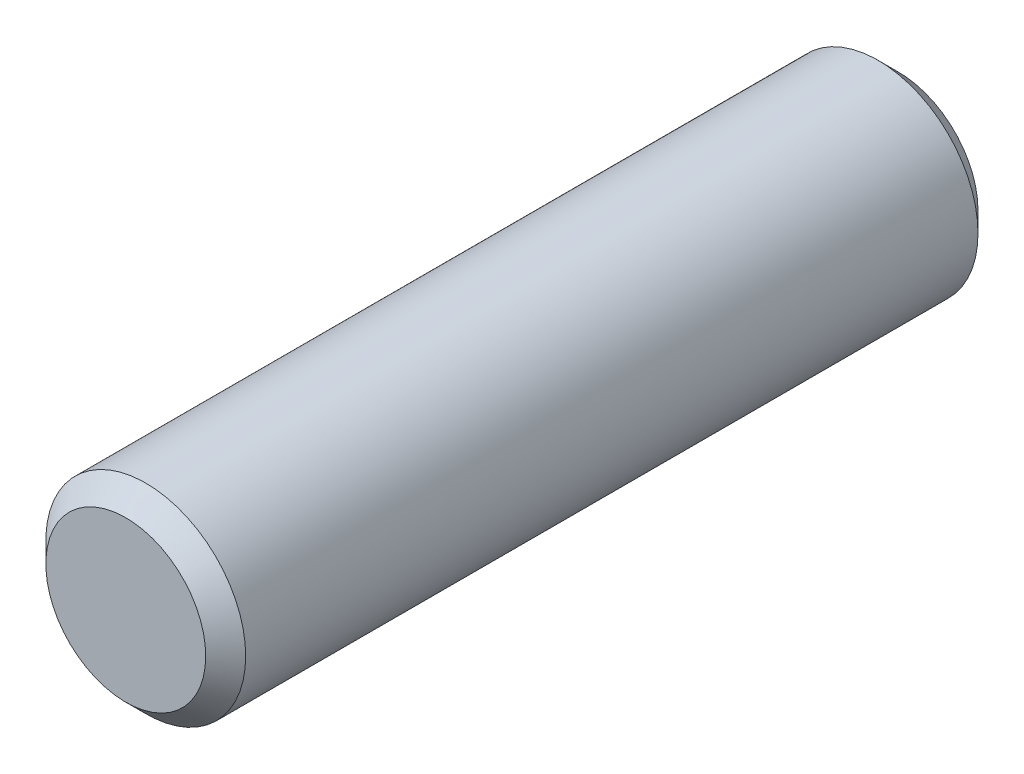
from build123d import *

# Parameters (mm, degrees)
SKETCH3_R           = 7.9375
BOSS_EXTRUDE1_DEPTH = 30.675
CHAMFER1_SIZE       = 1.5875


with BuildPart() as part:
    # Sketch3 → Boss-Extrude1 (new body, symmetric)
    with BuildSketch(Plane.XY):
        Circle(SKETCH3_R)
    extrude(amount=BOSS_EXTRUDE1_DEPTH, both=True)

    # Chamfer1
    chamfer1_edges = [part.edges().sort_by_distance(p)[0] for p in [
        (-7.9375, 0, -30.675),
        (-7.9375, 0, 30.675),
    ]]
    chamfer(chamfer1_edges, length=CHAMFER1_SIZE)


solid = part.part
